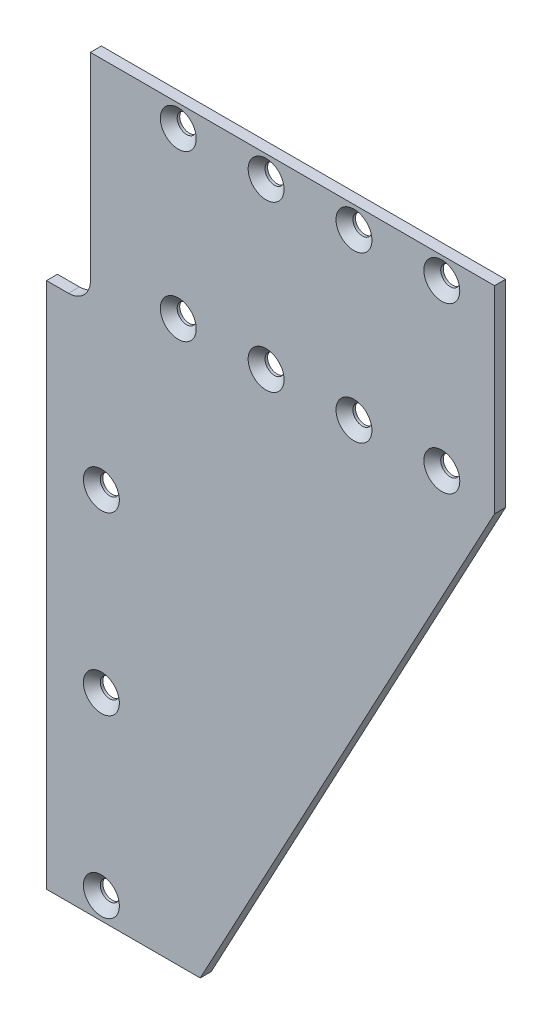
from build123d import *

# Parameters (mm, degrees)
BOSS_EXTRUDE1_DEPTH                       = 3.175
CSK_FOR_0_FLAT_HEAD_MACHINE_SCREW_2_COUNT = 2
CSK_FOR_0_FLAT_HEAD_MACHINE_SCREW_2_PITCH = 47.625
LPATTERN1_COUNT                           = 4
LPATTERN1_PITCH                           = 25.4
LPATTERN2_COUNT                           = 3
LPATTERN2_PITCH                           = 50.8


with BuildPart() as part:
    # Sketch1 → Boss-Extrude1 (new body)
    with BuildSketch(Plane.XY):
        with BuildLine():
            Line((0, 0), (0, 152.4))
            Line((0, 152.4), (6.35, 152.4))
            ThreePointArc((6.35, 152.4), (10.840128061, 154.259871939), (12.7, 158.75))
            Line((12.7, 158.75), (12.7, 215.9))
            Line((12.7, 215.9), (129.54, 215.9))
            Line((129.54, 215.9), (129.54, 158.75))
            Line((129.54, 158.75), (44.45, 0))
            Line((44.45, 0), (0, 0))
        make_face()
    extrude(amount=-BOSS_EXTRUDE1_DEPTH)

    # Sketch3 → CSK for _0 Flat Head Machine Screw _100 (revolve, cut)
    with BuildSketch(Plane(origin=(38.1, 209.55, 0), x_dir=(0, -1, 0), z_dir=(1, 0, 0))):
        Polygon((0, 0), (0, 3.175), (2.7559, 3.175), (2.7559, 2.4384), (5.1943, 0), align=None)
    csk_for_0_flat_head_machine_screw_100 = revolve(axis=Axis((38.1, 209.55, 6.35), (0, 0, -1)), mode=Mode.SUBTRACT)

    # CSK for _0 Flat Head Machine Screw _ 2: CSK for _0 Flat Head Machine Screw _100 ×2
    with Locations(*[(0, -i * CSK_FOR_0_FLAT_HEAD_MACHINE_SCREW_2_PITCH, 0) for i in range(1, CSK_FOR_0_FLAT_HEAD_MACHINE_SCREW_2_COUNT)]):
        add(csk_for_0_flat_head_machine_screw_100, mode=Mode.SUBTRACT)

    # LPattern1: CSK for _0 Flat Head Machine Screw _100 ×4
    with Locations(*[(i * LPATTERN1_PITCH, 0, 0) for i in range(1, LPATTERN1_COUNT)]):
        add(csk_for_0_flat_head_machine_screw_100, mode=Mode.SUBTRACT)

    # LPattern1 copy 1 sketch → LPattern1 copy 1 (revolve, cut)
    with BuildSketch(Plane(origin=(63.5, 161.925, 0), x_dir=(0, -1, 0), z_dir=(1, 0, 0))):
        Polygon((0, 0), (0, 3.175), (2.7559, 3.175), (2.7559, 2.4384), (5.1943, 0), align=None)
    revolve(axis=Axis((63.5, 161.925, 6.35), (0, 0, -1)), mode=Mode.SUBTRACT)

    # LPattern1 copy 2 sketch → LPattern1 copy 2 (revolve, cut)
    with BuildSketch(Plane(origin=(88.9, 161.925, 0), x_dir=(0, -1, 0), z_dir=(1, 0, 0))):
        Polygon((0, 0), (0, 3.175), (2.7559, 3.175), (2.7559, 2.4384), (5.1943, 0), align=None)
    revolve(axis=Axis((88.9, 161.925, 6.35), (0, 0, -1)), mode=Mode.SUBTRACT)

    # LPattern1 copy 3 sketch → LPattern1 copy 3 (revolve, cut)
    with BuildSketch(Plane(origin=(114.3, 161.925, 0), x_dir=(0, -1, 0), z_dir=(1, 0, 0))):
        Polygon((0, 0), (0, 3.175), (2.7559, 3.175), (2.7559, 2.4384), (5.1943, 0), align=None)
    revolve(axis=Axis((114.3, 161.925, 6.35), (0, 0, -1)), mode=Mode.SUBTRACT)

    # Sketch4 → CSK for _0 Flat Head Machine Screw _ 3 (revolve, cut)
    with BuildSketch(Plane(origin=(15.875, 107.95, 0), x_dir=(0, -1, 0), z_dir=(1, 0, 0))):
        Polygon((0, 0), (0, 3.175), (2.7559, 3.175), (2.7559, 2.4384), (5.1943, 0), align=None)
    csk_for_0_flat_head_machine_screw_3 = revolve(axis=Axis((15.875, 107.95, 6.35), (0, 0, -1)), mode=Mode.SUBTRACT)

    # LPattern2: CSK for _0 Flat Head Machine Screw _ 3 ×3
    with Locations(*[(0, -i * LPATTERN2_PITCH, 0) for i in range(1, LPATTERN2_COUNT)]):
        add(csk_for_0_flat_head_machine_screw_3, mode=Mode.SUBTRACT)


solid = part.part
